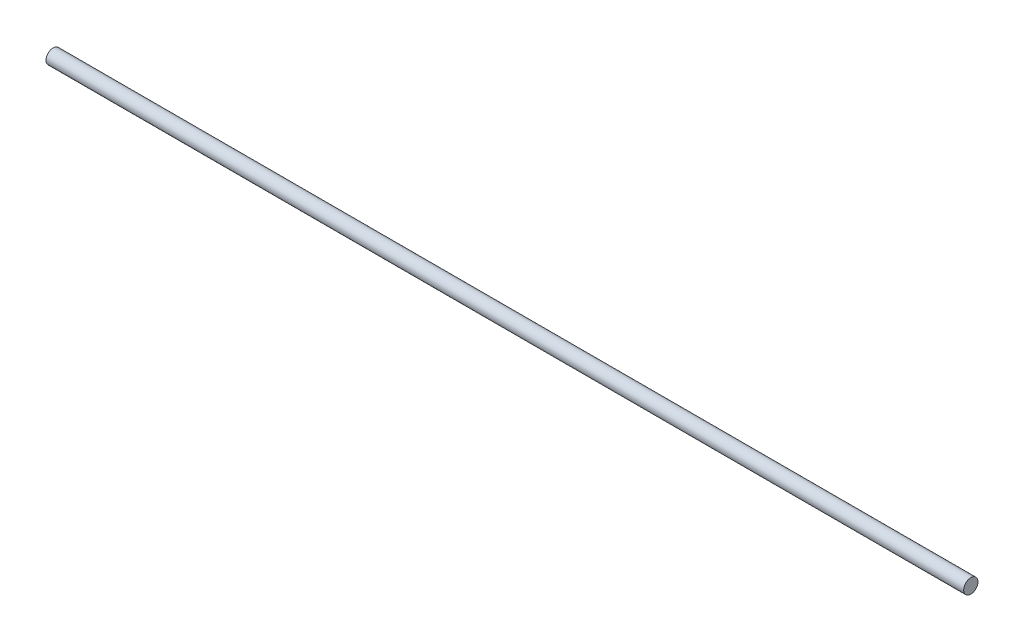
from build123d import *

# Parameters (mm, degrees)
SKETCH1_R           = 4.7625
BOSS_EXTRUDE1_DEPTH = 609.6


with BuildPart() as part:
    # Sketch1 → Boss-Extrude1 (new body)
    with BuildSketch(Plane(origin=(0, 0, 0), x_dir=(0, 0, -1), z_dir=(1, 0, 0))):
        Circle(SKETCH1_R)
    extrude(amount=BOSS_EXTRUDE1_DEPTH)


solid = part.part
